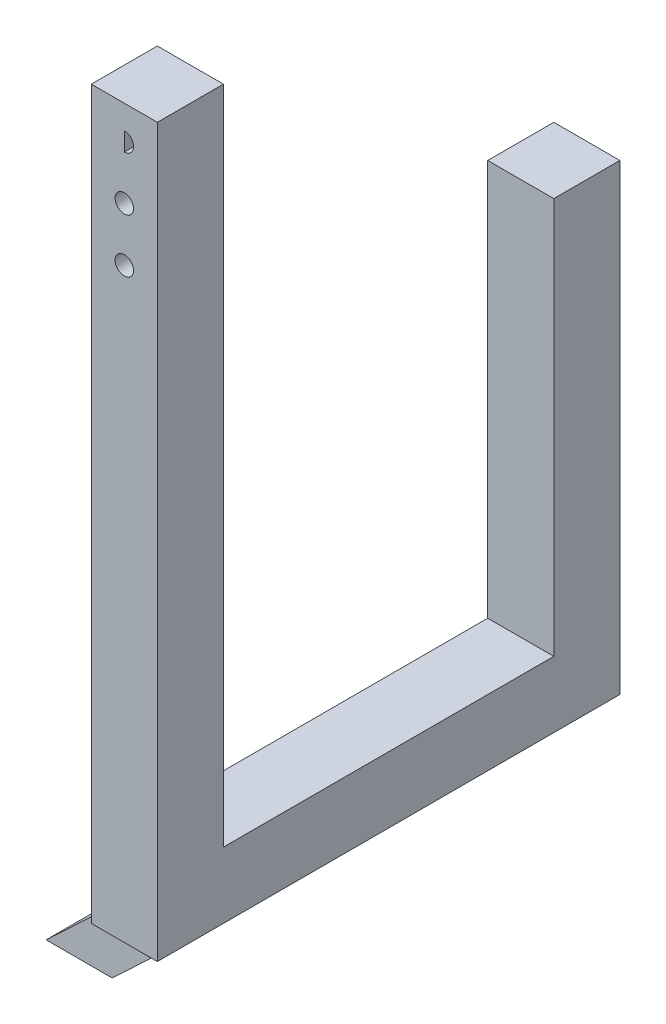
from build123d import *

# Parameters (mm, degrees)
SKETCH1_W           = 12.7
SKETCH1_H           = 139.7
BOSS_EXTRUDE1_DEPTH = 12.7
SKETCH2_W           = 63.5
SKETCH2_H           = 12.7
BOSS_EXTRUDE2_DEPTH = 12.7
SKETCH3_W           = 12.7
SKETCH3_H           = 88.9
BOSS_EXTRUDE3_DEPTH = 12.7
SKETCH6_R           = 1.778
CUT_EXTRUDE1_DEPTH  = 89.9
BOSS_EXTRUDE7_START = -19.05
BOSS_EXTRUDE7_DEPTH = 12.7
BOSS_EXTRUDE8_START = 44.45
BOSS_EXTRUDE8_DEPTH = 12.7


with BuildPart() as part:
    # Sketch1 → Boss-Extrude1 (new body)
    with BuildSketch(Plane.XY):
        with Locations((6.35, 69.85)):
            Rectangle(SKETCH1_W, SKETCH1_H)
    extrude(amount=BOSS_EXTRUDE1_DEPTH)

    # Sketch2 → Boss-Extrude2 (add)
    with BuildSketch(Plane.ZY):
        with Locations((-31.75, 6.35)):
            Rectangle(SKETCH2_W, SKETCH2_H)
    extrude(amount=-BOSS_EXTRUDE2_DEPTH)

    # Sketch3 → Boss-Extrude3 (add)
    with BuildSketch(Plane.ZY):
        with Locations((-69.85, 44.45)):
            Rectangle(SKETCH3_W, SKETCH3_H)
    extrude(amount=-BOSS_EXTRUDE3_DEPTH)

    # Sketch6 → Cut-Extrude1 (cut, through all)
    with BuildSketch(Plane.XY.offset(12.7)):
        with BuildLine():
            ThreePointArc((6.35, 131.572), (8.128, 133.35), (6.35, 135.128))
            Line((6.35, 135.128), (6.35, 131.572))
        make_face()
        with Locations((6.35, 112.7125)):
            Circle(SKETCH6_R)
        with Locations((6.35, 123.03125)):
            Circle(SKETCH6_R)
    extrude(amount=-CUT_EXTRUDE1_DEPTH, mode=Mode.SUBTRACT)

    # Sketch7 → Boss-Extrude7 (add)
    with BuildSketch(Plane.XY.offset(12.7).offset(BOSS_EXTRUDE7_START)):
        Polygon((0, 0), (-27.729644095, -26.128085241), (-15.029644095, -26.128085241), (12.7, 0), align=None)
    extrude(amount=-BOSS_EXTRUDE7_DEPTH)

    # Sketch10 → Boss-Extrude8 (add)
    with BuildSketch(Plane(origin=(0, 0, -19.05), x_dir=(-1, 0, 0), z_dir=(0, 0, -1)).offset(BOSS_EXTRUDE8_START)):
        Polygon((-12.7, 0), (15.029644095, -26.128085241), (27.729644095, -26.128085241), (0, 0), align=None)
    extrude(amount=BOSS_EXTRUDE8_DEPTH)


solid = part.part
